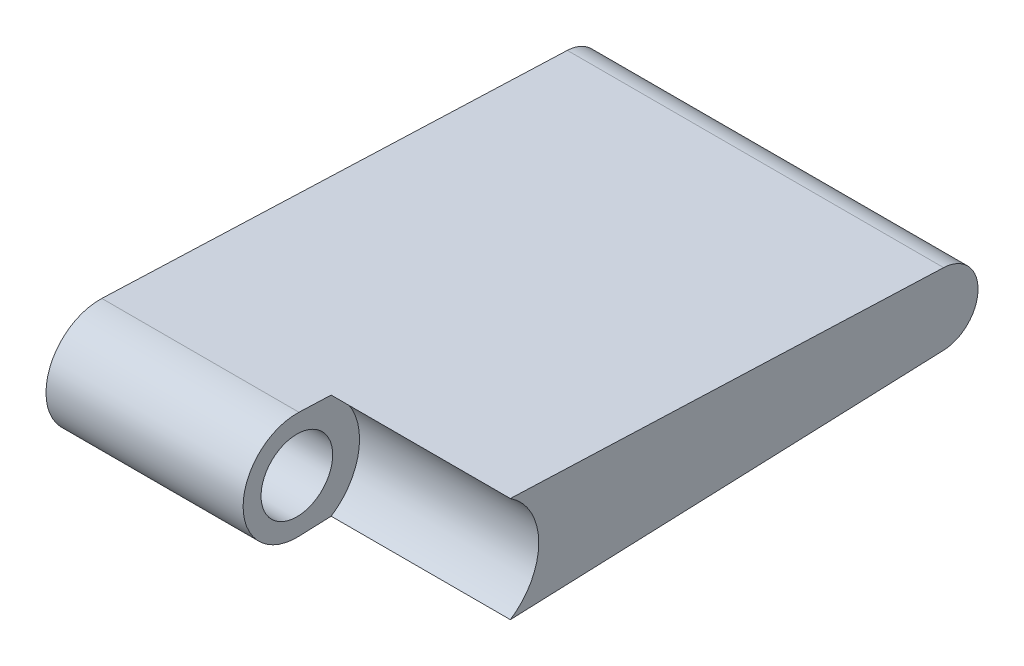
from build123d import *

# Parameters (mm, degrees)
BOSS_EXTRUDE1_DEPTH = 16.46682
SKETCH2_R           = 2.7432
CUT_EXTRUDE1_DEPTH  = 7.84098
SKETCH3_R           = 1.56718
CUT_EXTRUDE2_DEPTH  = 9.62584


with BuildPart() as part:
    # Sketch1 → Boss-Extrude1 (new body)
    with BuildSketch(Plane(origin=(0, 0, 0), x_dir=(0, 0, -1), z_dir=(1, 0, 0))):
        with BuildLine():
            Line((-10.13615668, 2.350298814), (10.23492888, 1.566019836))
            ThreePointArc((10.23492888, 1.566019836), (11.741817718, 0), (10.23492888, -1.566019836))
            Line((10.23492888, -1.566019836), (-10.13615668, -2.350298814))
            ThreePointArc((-10.13615668, -2.350298814), (-12.578682282, 0), (-10.13615668, 2.350298814))
        make_face()
    extrude(amount=-BOSS_EXTRUDE1_DEPTH)

    # Sketch2 → Cut-Extrude1 (cut)
    with BuildSketch(Plane(origin=(0, 0, 0), x_dir=(0, 0, -1), z_dir=(1, 0, 0))):
        with Locations((-10.226642282, 0)):
            Circle(SKETCH2_R)
    extrude(amount=-CUT_EXTRUDE1_DEPTH, mode=Mode.SUBTRACT)

    # Sketch3 → Cut-Extrude2 (cut, through all)
    with BuildSketch(Plane(origin=(-7.84098, 0, 0), x_dir=(0, 0, -1), z_dir=(1, 0, 0))):
        with Locations((-10.226642282, 0)):
            Circle(SKETCH3_R)
    extrude(amount=-CUT_EXTRUDE2_DEPTH, mode=Mode.SUBTRACT)


solid = part.part
